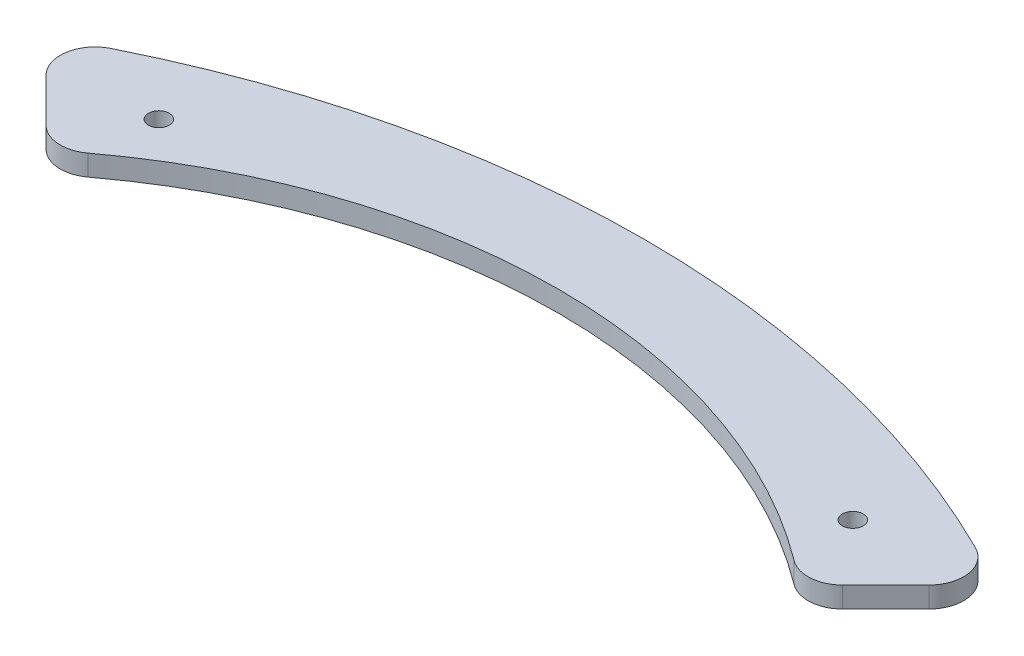
from build123d import *

# Parameters (mm, degrees)
BOSS_EXTRUDE1_DEPTH = 3
FILLET1_R           = 5
CUT_EXTRUDE1_REACH  = 5
SKETCH2_R           = 1.5


with BuildPart() as part:
    # Sketch1 → Boss-Extrude1 (new body)
    with BuildSketch(Plane(origin=(0, 0, 0), x_dir=(1, 0, 0), z_dir=(0, 1, 0))):
        with BuildLine():
            Line((-68.408481347, 122.148596717), (-54.266345723, 108.006461093))
            ThreePointArc((-54.266345723, 108.006461093), (0, 127.583500889), (54.266345723, 108.006461093))
            Line((54.266345723, 108.006461093), (68.408481347, 122.148596717))
            ThreePointArc((68.408481347, 122.148596717), (0, 140), (-68.408481347, 122.148596717))
        make_face()
    extrude(amount=BOSS_EXTRUDE1_DEPTH)

    # Fillet1
    fillet1_edges = [part.edges().sort_by_distance(p)[0] for p in [
        (68.408481347, 1.5, -122.148596717),
        (54.266345723, 1.5, -108.006461093),
        (-54.266345723, 1.5, -108.006461093),
        (-68.408481347, 1.5, -122.148596717),
    ]]
    fillet(fillet1_edges, radius=FILLET1_R)

    # Sketch2 → Cut-Extrude1 (cut, up to next)
    with BuildSketch(Plane(origin=(0, 3, 0), x_dir=(1, 0, 0), z_dir=(0, 1, 0)), mode=Mode.PRIVATE) as cut_extrude1_sk1:
        with Locations((-50, 120)):
            Circle(SKETCH2_R)
    cut_extrude1_tool1 = extrude(cut_extrude1_sk1.sketch, amount=-CUT_EXTRUDE1_REACH, mode=Mode.PRIVATE) & part.part
    add(cut_extrude1_tool1.solids().sort_by_distance((-50, 3, -120))[0], mode=Mode.SUBTRACT)
    # Sketch2 → Cut-Extrude1 (cut, up to next)
    with BuildSketch(Plane(origin=(0, 3, 0), x_dir=(1, 0, 0), z_dir=(0, 1, 0)), mode=Mode.PRIVATE) as cut_extrude1_sk2:
        with Locations((50, 120)):
            Circle(SKETCH2_R)
    cut_extrude1_tool2 = extrude(cut_extrude1_sk2.sketch, amount=-CUT_EXTRUDE1_REACH, mode=Mode.PRIVATE) & part.part
    add(cut_extrude1_tool2.solids().sort_by_distance((50, 3, -120))[0], mode=Mode.SUBTRACT)


solid = part.part
